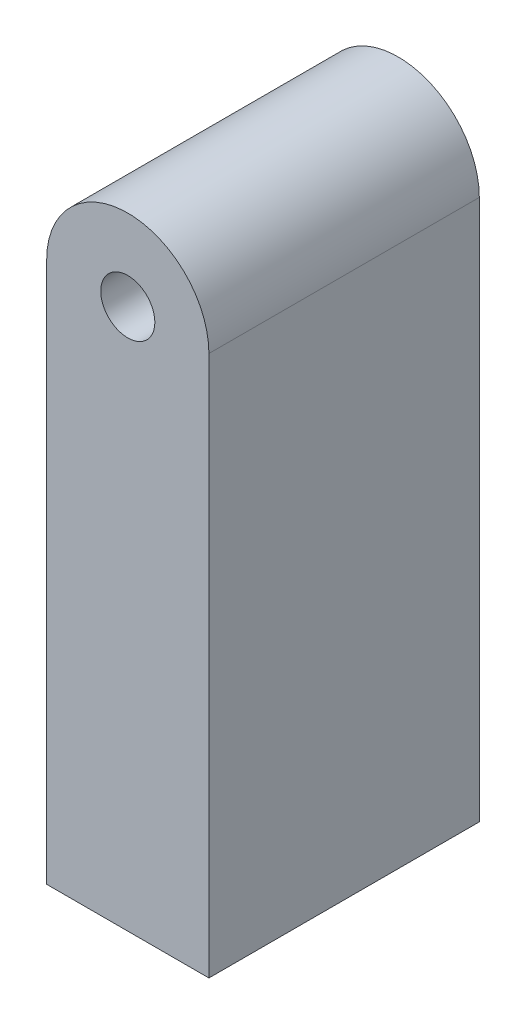
from build123d import *

# Parameters (mm, degrees)
BOSS_EXTRUDE1_DEPTH = 1.27


with BuildPart() as part:
    # Sketch2 → Boss-Extrude1 (new body)
    with BuildSketch(Plane.XY):
        with BuildLine():
            ThreePointArc((0.381, 1.27), (0, 1.651), (-0.381, 1.27))
            Line((-0.381, 1.27), (-0.127, 1.27))
            ThreePointArc((-0.127, 1.27), (0, 1.397), (0.127, 1.27))
            Line((0.127, 1.27), (0.381, 1.27))
        make_face()
        with BuildLine():
            Line((-0.127, 1.27), (-0.381, 1.27))
            ThreePointArc((-0.381, 1.27), (0, 0.889), (0.381, 1.27))
            Line((0.381, 1.27), (0.127, 1.27))
            ThreePointArc((0.127, 1.27), (0, 1.143), (-0.127, 1.27))
        make_face()
        with BuildLine():
            Line((-0.381, 1.27), (-0.381, -1.27))
            Line((-0.381, -1.27), (0.381, -1.27))
            Line((0.381, -1.27), (0.381, 1.27))
            ThreePointArc((0.381, 1.27), (0, 0.889), (-0.381, 1.27))
        make_face()
    extrude(amount=BOSS_EXTRUDE1_DEPTH)


solid = part.part
